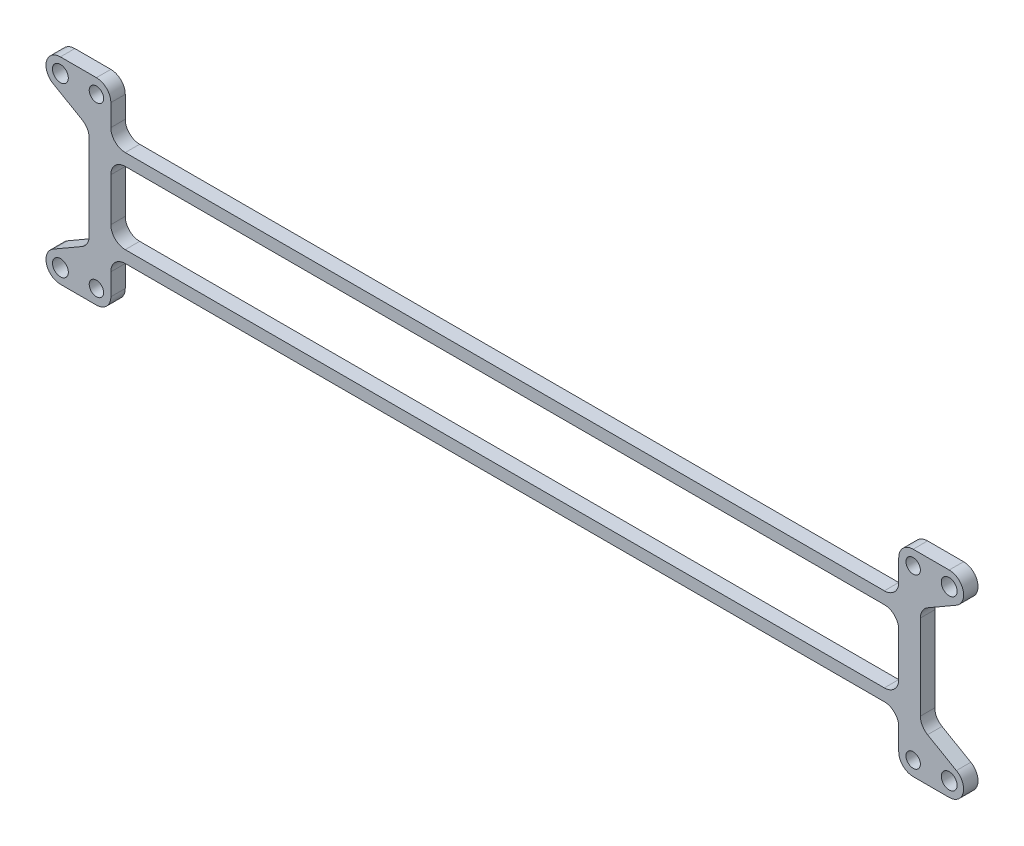
from build123d import *

# Parameters (mm, degrees)
ESBO_O1_R                = 1.65
ESBO_O1_R_2              = 1.5
RESSALTO_EXTRUS_O1_DEPTH = 3


with BuildPart() as part:
    # Esboço1 → Ressalto-extrusão1 (new body)
    with BuildSketch(Plane.XY):
        with BuildLine():
            Line((-92.5, -20.5), (-85, -20.5))
            ThreePointArc((-85, -20.5), (-82.878679656, -19.621320344), (-82, -17.5))
            Line((-82, -17.5), (-82, -13))
            ThreePointArc((-82, -13), (-81.121320344, -10.878679656), (-79, -10))
            Line((-79, -10), (0, -10))
            Line((0, -10), (0, -7.5))
            Line((0, -7.5), (-79, -7.5))
            ThreePointArc((-79, -7.5), (-81.121320344, -6.621320344), (-82, -4.5))
            Line((-82, -4.5), (-82, 4.5))
            ThreePointArc((-82, 4.5), (-81.121320344, 6.621320344), (-79, 7.5))
            Line((-79, 7.5), (0, 7.5))
            Line((0, 7.5), (0, 10))
            Line((0, 10), (-79, 10))
            ThreePointArc((-79, 10), (-81.121320344, 10.878679656), (-82, 13))
            Line((-82, 13), (-82, 17.5))
            ThreePointArc((-82, 17.5), (-82.878679656, 19.621320344), (-85, 20.5))
            Line((-85, 20.5), (-92.5, 20.5))
            ThreePointArc((-92.5, 20.5), (-95.397777479, 18.276457135), (-94, 14.901923789))
            Line((-94, 14.901923789), (-88, 11.437822174))
            ThreePointArc((-88, 11.437822174), (-86.901923789, 10.339745962), (-86.5, 8.839745962))
            Line((-86.5, 8.839745962), (-86.5, -8.839745962))
            ThreePointArc((-86.5, -8.839745962), (-86.901923789, -10.339745962), (-88, -11.437822174))
            Line((-88, -11.437822174), (-94, -14.901923789))
            ThreePointArc((-94, -14.901923789), (-95.397777479, -18.276457135), (-92.5, -20.5))
        make_face()
        with Locations((-92.5, 17.5)):
            Circle(ESBO_O1_R, mode=Mode.SUBTRACT)
        with Locations((-92.5, -17.5)):
            Circle(ESBO_O1_R, mode=Mode.SUBTRACT)
        with Locations((-85, 17.5)):
            Circle(ESBO_O1_R_2, mode=Mode.SUBTRACT)
        with Locations((-85, -17.5)):
            Circle(ESBO_O1_R_2, mode=Mode.SUBTRACT)
    ressalto_extrus_o1 = extrude(amount=RESSALTO_EXTRUS_O1_DEPTH)

    # Espelhar1: Ressalto-extrusão1 across plane
    add(ressalto_extrus_o1.mirror(Plane(origin=(0, 0, 0), x_dir=(0, 0, 1), z_dir=(1, 0, 0))))


solid = part.part
